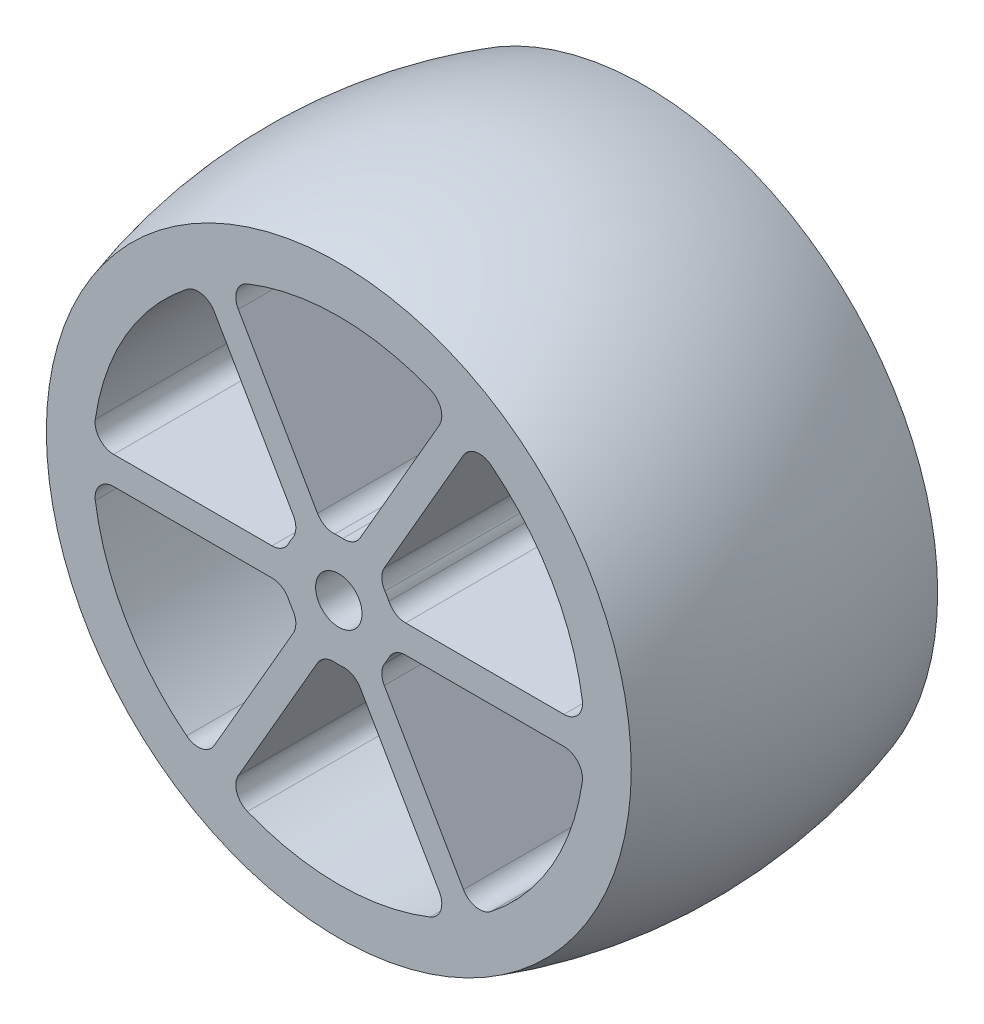
from build123d import *

# Parameters (mm, degrees)
SCHNITT_LINEAR_AUSTRAGEN1_DEPTH = 59.31809342
VERRUNDUNG1_R                   = 2
KREISMUSTER1_COUNT              = 6
VERRUNDUNG1_OF_KREISMUSTER1_R   = 2
SKIZZE7_R                       = 2.5
SCHNITT_LINEAR_AUSTRAGEN3_DEPTH = 59.31809342


with BuildPart() as part:
    # Skizze4 → Rotation1 (revolve)
    with BuildSketch(Plane(origin=(0, 0, 0), x_dir=(0, 0, -1), z_dir=(1, 0, 0))):
        with BuildLine():
            Line((-16.5, 31.5), (-16.5, 0))
            Line((-16.5, 0), (16.5, 0))
            Line((16.5, 0), (16.5, 31.5))
            ThreePointArc((16.5, 31.5), (0, 34), (-16.5, 31.5))
        make_face()
    revolve(axis=Axis((0, 0, 6.739526199), (0, 0, -1)))

    # Skizze5 → Schnitt-Linear austragen1 (cut, through all)
    with BuildSketch(Plane.XY.offset(16.5)):
        with BuildLine():
            Line((-11.92971845, 23.662878475), (-1.605699404, 5.781152949))
            ThreePointArc((-1.605699404, 5.781152949), (0, 6), (1.605699404, 5.781152949))
            Line((1.605699404, 5.781152949), (11.92971845, 23.662878475))
            ThreePointArc((11.92971845, 23.662878475), (0, 26.5), (-11.92971845, 23.662878475))
        make_face()
    schnitt_linear_austragen1 = extrude(amount=-SCHNITT_LINEAR_AUSTRAGEN1_DEPTH, mode=Mode.SUBTRACT)

    # Verrundung1
    verrundung1_edges = [part.edges().sort_by_distance(p)[0] for p in [
        (11.92971845, 23.662878475, 0),
        (1.605699404, 5.781152949, 0),
        (-1.605699404, 5.781152949, 0),
        (-11.92971845, 23.662878475, 0),
    ]]
    fillet(verrundung1_edges, radius=VERRUNDUNG1_R)

    # Kreismuster1: Schnitt-Linear austragen1 ×6 about axis
    kreismuster1_axis = Axis((0, 0, 18.15), (0, 0, -1))
    for i in range(1, KREISMUSTER1_COUNT):
        add(schnitt_linear_austragen1.rotate(kreismuster1_axis, i * 360 / KREISMUSTER1_COUNT), mode=Mode.SUBTRACT)

    # Verrundung1 of Kreismuster1
    verrundung1_of_kreismuster1_edges = [part.edges().sort_by_distance(p)[0] for p in [
        (26.457513111, 1.5, 0),
        (5.809475019, 1.5, 0),
        (4.203775615, 4.281152949, 0),
        (14.527794661, 22.162878475, 0),
        (14.527794661, -22.162878475, 0),
        (4.203775615, -4.281152949, 0),
        (5.809475019, -1.5, 0),
        (26.457513111, -1.5, 0),
        (-11.92971845, -23.662878475, 0),
        (-1.605699404, -5.781152949, 0),
        (1.605699404, -5.781152949, 0),
        (11.92971845, -23.662878475, 0),
        (-26.457513111, -1.5, 0),
        (-5.809475019, -1.5, 0),
        (-4.203775615, -4.281152949, 0),
        (-14.527794661, -22.162878475, 0),
        (-14.527794661, 22.162878475, 0),
        (-4.203775615, 4.281152949, 0),
        (-5.809475019, 1.5, 0),
        (-26.457513111, 1.5, 0),
    ]]
    fillet(verrundung1_of_kreismuster1_edges, radius=VERRUNDUNG1_OF_KREISMUSTER1_R)

    # Skizze7 → Schnitt-Linear austragen3 (cut, through all)
    with BuildSketch(Plane.XY.offset(16.5)):
        Circle(SKIZZE7_R)
    extrude(amount=-SCHNITT_LINEAR_AUSTRAGEN3_DEPTH, mode=Mode.SUBTRACT)


solid = part.part
